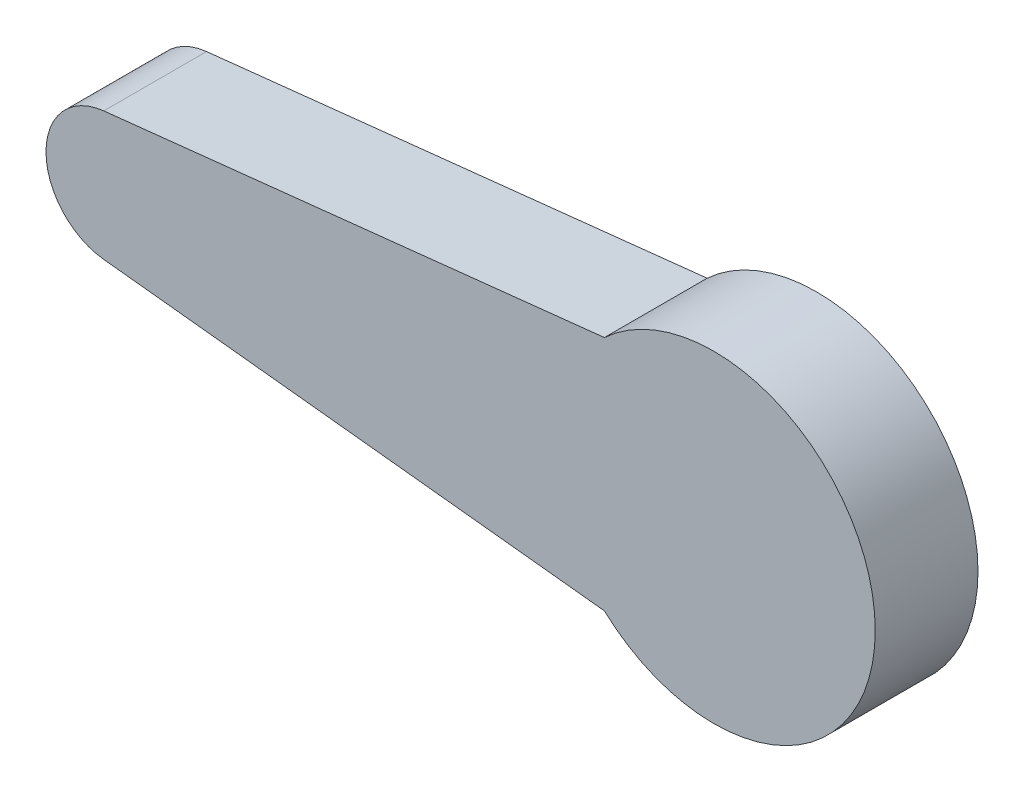
from build123d import *

# Parameters (mm, degrees)
BOSS_EXTRUDE6_DEPTH = 4
CUT_EXTRUDE1_DEPTH  = 2


with BuildPart() as part:
    # Sketch2 → Boss-Extrude6 (new body)
    with BuildSketch(Plane.XY):
        with BuildLine():
            Line((7.936945185, 4.607509822), (-11.550211463, 2.50416625))
            ThreePointArc((-11.550211463, 2.50416625), (-13.798635322, 0), (-11.550211463, -2.50416625))
            Line((-11.550211463, -2.50416625), (7.936945185, -4.607509822))
            ThreePointArc((7.936945185, -4.607509822), (18.479455181, 0), (7.936945185, 4.607509822))
        make_face()
    extrude(amount=BOSS_EXTRUDE6_DEPTH)

    # Sketch1 → Cut-Extrude1 (cut)
    with BuildSketch(Plane.XY):
        with BuildLine():
            Line((-2.308259951, 2.498066053), (9.375044145, 3.190055955))
            add(Edge.make_bspline(
                [(9.375044145, 3.190055955), (9.743762717, 3.535051607), (10.542113364, 3.885379294), (11.739855888, 4.053778423), (12.781606273, 3.904003548), (13.647647588, 3.58835165), (14.172524986, 3.123610305), (14.749448402, 2.727996587), (15.239395752, 2.01553181), (15.653528757, 1.050879588), (15.788992815, -0.000691818), (15.651665108, -1.048112313), (15.246850359, -2.025217286), (14.603250264, -2.863967716), (13.764299096, -3.507779486), (12.787785525, -3.91194775), (11.73820132, -4.051651269), (10.542857019, -3.886335356), (9.743600409, -3.534842939), (9.375044145, -3.190055955)],
                knots=[0, 0, 0, 0, 0.085136877, 0.144403023, 0.203669169, 0.262935434, 0.297502717, 0.322201499, 0.3814676, 0.440733879, 0.5, 0.559266121, 0.6185324, 0.677798501, 0.737064566, 0.796330831, 0.855596977, 0.914863123, 1, 1, 1, 1], degree=3))
            Line((9.375044145, -3.190055955), (-2.308259951, -2.498066053))
            add(Edge.make_bspline(
                [(-2.308259951, -2.498066053), (-2.730270965, -2.498681523), (-3.365255191, -2.317767142), (-4.051947117, -1.791219452), (-4.45450445, -1.266528616), (-4.707556493, -0.655614107), (-4.793872131, 0), (-4.707556493, 0.655614107), (-4.45450445, 1.266528616), (-4.051947117, 1.791219452), (-3.365255191, 2.317767142), (-2.730270965, 2.498681523), (-2.308259951, 2.498066053)],
                knots=[0, 0, 0, 0, 0.162547316, 0.2469105, 0.331273485, 0.415637006, 0.5, 0.584362994, 0.668726515, 0.7530895, 0.837452684, 1, 1, 1, 1], degree=3))
        make_face()
    extrude(amount=CUT_EXTRUDE1_DEPTH, mode=Mode.SUBTRACT)


solid = part.part
